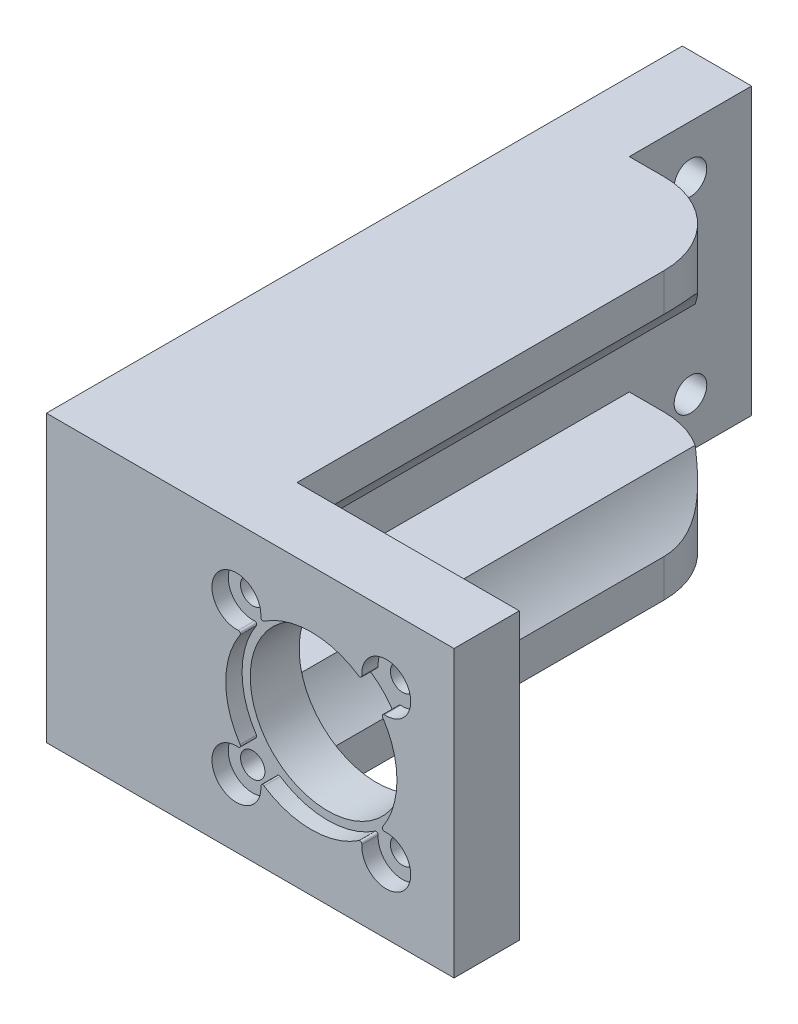
from build123d import *

# Parameters (mm, degrees)
SKETCH1_W           = 50
SKETCH1_H           = 35
SKETCH1_R           = 9.5
SKETCH1_R_2         = 1.5
BOSS_EXTRUDE3_DEPTH = 6
SKETCH4_W           = 50
SKETCH4_H           = 35
BOSS_EXTRUDE5_DEPTH = 2
BOSS_EXTRUDE6_DEPTH = 55
SKETCH9_R           = 2
CUT_EXTRUDE1_DEPTH  = 8.5
BOSS_EXTRUDE7_DEPTH = 15
FILLET1_R           = 10
FILLET8_R           = 10
SKETCH16_R          = 2
CUT_EXTRUDE2_DEPTH  = 8.5


with BuildPart() as part:
    # Sketch1 → Boss-Extrude3 (new body)
    with BuildSketch(Plane.XY):
        with Locations((25, 17.5)):
            Rectangle(SKETCH1_W, SKETCH1_H)
        with Locations((32.5, 17.5)):
            Circle(SKETCH1_R, mode=Mode.SUBTRACT)
        with Locations((41.692388155, 26.692388155)):
            Circle(SKETCH1_R_2, mode=Mode.SUBTRACT)
        with Locations((41.692388155, 8.307611845)):
            Circle(SKETCH1_R_2, mode=Mode.SUBTRACT)
        with Locations((23.307611845, 8.307611845)):
            Circle(SKETCH1_R_2, mode=Mode.SUBTRACT)
        with Locations((23.307611845, 26.692388155)):
            Circle(SKETCH1_R_2, mode=Mode.SUBTRACT)
    extrude(amount=BOSS_EXTRUDE3_DEPTH)

    # Sketch4 → Boss-Extrude5 (add)
    with BuildSketch(Plane.XY.offset(6)):
        with Locations((25, 17.5)):
            Rectangle(SKETCH4_W, SKETCH4_H)
        with BuildLine():
            ThreePointArc((26.299419693, 26.47083501), (21.186291501, 28.813708499), (23.52916499, 23.700580307))
            ThreePointArc((23.52916499, 23.700580307), (23.763454109, 23.57743344), (23.755822455, 23.312861521))
            ThreePointArc((23.755822455, 23.312861521), (22, 17.5), (23.755822455, 11.687138479))
            ThreePointArc((23.755822455, 11.687138479), (23.763454109, 11.42256656), (23.52916499, 11.299419693))
            ThreePointArc((23.52916499, 11.299419693), (21.186291501, 6.186291501), (26.299419693, 8.52916499))
            ThreePointArc((26.299419693, 8.52916499), (26.42256656, 8.763454109), (26.687138479, 8.755822455))
            ThreePointArc((26.687138479, 8.755822455), (32.5, 7), (38.312861521, 8.755822455))
            ThreePointArc((38.312861521, 8.755822455), (38.57743344, 8.763454109), (38.700580307, 8.52916499))
            ThreePointArc((38.700580307, 8.52916499), (43.813708499, 6.186291501), (41.47083501, 11.299419693))
            ThreePointArc((41.47083501, 11.299419693), (41.236545891, 11.42256656), (41.244177545, 11.687138479))
            ThreePointArc((41.244177545, 11.687138479), (43, 17.5), (41.244177545, 23.312861521))
            ThreePointArc((41.244177545, 23.312861521), (41.236545891, 23.57743344), (41.47083501, 23.700580307))
            ThreePointArc((41.47083501, 23.700580307), (43.813708499, 28.813708499), (38.700580307, 26.47083501))
            ThreePointArc((38.700580307, 26.47083501), (38.57743344, 26.236545891), (38.312861521, 26.244177545))
            ThreePointArc((38.312861521, 26.244177545), (32.5, 28), (26.687138479, 26.244177545))
            ThreePointArc((26.687138479, 26.244177545), (26.42256656, 26.236545891), (26.299419693, 26.47083501))
        make_face(mode=Mode.SUBTRACT)
    extrude(amount=BOSS_EXTRUDE5_DEPTH)

    # Sketch8 → Boss-Extrude6 (add)
    with BuildSketch(Plane(origin=(0, 0, 0), x_dir=(-1, 0, 0), z_dir=(0, 0, -1))):
        with BuildLine():
            Line((-8.5, 35), (-22.740329685, 35))
            Line((-22.740329685, 35), (-22.740329685, 30.367452558))
            ThreePointArc((-22.740329685, 30.367452558), (-20.171344576, 27.9320063), (-18.194683381, 24.99535966))
            Line((-18.194683381, 24.99535966), (-18.194683381, 25))
            Line((-18.194683381, 25), (-8.5, 25))
            Line((-8.5, 25), (-8.5, 10.000000197))
            Line((-8.5, 10.000000197), (-18.197115572, 10.000000197))
            ThreePointArc((-18.197115572, 10.000000197), (-20.17303677, 7.065994176), (-22.740329685, 4.632547442))
            Line((-22.740329685, 4.632547442), (-22.740329685, 0))
            Line((-22.740329685, 0), (-8.5, 0))
            Line((-8.5, 0), (0, 0))
            Line((0, 0), (0, 10.000000197))
            Line((0, 10.000000197), (0, 25))
            Line((0, 25), (0, 35))
            Line((0, 35), (-8.5, 35))
        make_face()
    extrude(amount=BOSS_EXTRUDE6_DEPTH)

    # Sketch9 → Cut-Extrude1 (cut)
    with BuildSketch(Plane.ZY):
        with Locations((-7, 17.5)):
            Circle(SKETCH9_R)
        with Locations((-37, 17.5)):
            Circle(SKETCH9_R)
    extrude(amount=-CUT_EXTRUDE1_DEPTH, mode=Mode.SUBTRACT)

    # Sketch11 → Boss-Extrude7 (add)
    with BuildSketch(Plane(origin=(0, 0, -55), x_dir=(-1, 0, 0), z_dir=(0, 0, -1))):
        Polygon((-8.5, 10.000000197), (-8.5, 35), (0, 35), (0, 0), (-8.5, 0), align=None)
    extrude(amount=BOSS_EXTRUDE7_DEPTH)

    # Fillet1
    fillet1_edges = [part.edges().sort_by_distance(p)[0] for p in [
        (22.740329685, 32.683726279, -55),
    ]]
    fillet(fillet1_edges, radius=FILLET1_R)

    # Fillet8
    fillet8_edges = [part.edges().sort_by_distance(p)[0] for p in [
        (22.740329685, 2.316273721, -55),
    ]]
    fillet(fillet8_edges, radius=FILLET8_R)

    # Sketch16 → Cut-Extrude2 (cut)
    with BuildSketch(Plane(origin=(8.5, 0, 0), x_dir=(0, 0, -1), z_dir=(1, 0, 0))):
        with Locations((62.5, 29.000000197)):
            Circle(SKETCH16_R)
        with Locations((62.5, 6)):
            Circle(SKETCH16_R)
    extrude(amount=-CUT_EXTRUDE2_DEPTH, mode=Mode.SUBTRACT)


solid = part.part
